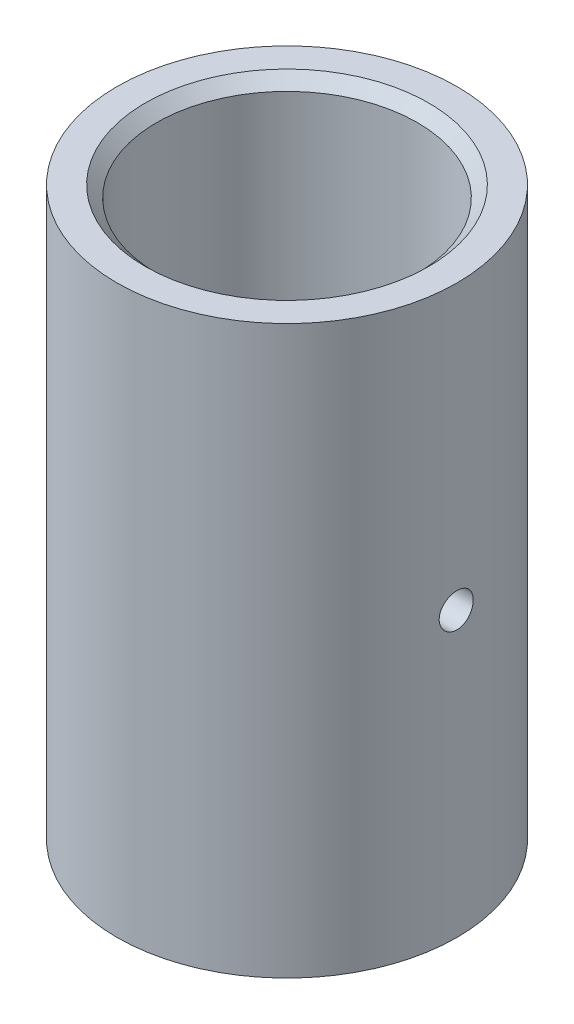
from build123d import *

# Parameters (mm, degrees)
SKETCH1_R                      = 7.5
BOSS_EXTRUDE1_DEPTH            = 25
SKETCH2_R                      = 5.75
CUT_EXTRUDE1_DEPTH             = 11
CHAMFER1_SIZE                  = 0.5
SKETCH3_R                      = 3.5
CUT_EXTRUDE2_DEPTH             = 10
CUT_EXTRUDE3_REACH             = 9.5
SKETCH4_R                      = 0.75
CUT_EXTRUDE3_DIRECTION_2_REACH = 9.5


with BuildPart() as part:
    # Sketch1 → Boss-Extrude1 (new body)
    with BuildSketch(Plane(origin=(0, 0, 0), x_dir=(1, 0, 0), z_dir=(0, 1, 0))):
        Circle(SKETCH1_R)
    extrude(amount=BOSS_EXTRUDE1_DEPTH)

    # Sketch2 → Cut-Extrude1 (cut)
    with BuildSketch(Plane(origin=(0, 25, 0), x_dir=(1, 0, 0), z_dir=(0, 1, 0))):
        Circle(SKETCH2_R)
    extrude(amount=-CUT_EXTRUDE1_DEPTH, mode=Mode.SUBTRACT)

    # Chamfer1
    chamfer1_edges = [part.edges().sort_by_distance(p)[0] for p in [
        (-5.75, 25, 0),
    ]]
    chamfer(chamfer1_edges, length=CHAMFER1_SIZE)

    # Sketch3 → Cut-Extrude2 (cut)
    with BuildSketch(Plane(origin=(0, 14, 0), x_dir=(1, 0, 0), z_dir=(0, 1, 0))):
        Circle(SKETCH3_R)
    extrude(amount=-CUT_EXTRUDE2_DEPTH, mode=Mode.SUBTRACT)

    # Sketch4 → Cut-Extrude3 (cut, up to next)
    with BuildSketch(Plane(origin=(0, 0, 0), x_dir=(0, 0, -1), z_dir=(1, 0, 0)), mode=Mode.PRIVATE) as cut_extrude3_sk1:
        with Locations((0, 12.5)):
            Circle(SKETCH4_R)
    cut_extrude3_tool1 = extrude(cut_extrude3_sk1.sketch, amount=-CUT_EXTRUDE3_REACH, mode=Mode.PRIVATE) & part.part
    add(cut_extrude3_tool1.solids().sort_by_distance((0, 12.5, 0))[0], mode=Mode.SUBTRACT)

    # Sketch4 → Cut-Extrude3 direction 2 (cut, up to next)
    with BuildSketch(Plane(origin=(0, 0, 0), x_dir=(0, 0, -1), z_dir=(1, 0, 0)), mode=Mode.PRIVATE) as cut_extrude3_direction_2_sk1:
        with Locations((0, 12.5)):
            Circle(SKETCH4_R)
    cut_extrude3_direction_2_tool1 = extrude(cut_extrude3_direction_2_sk1.sketch, amount=CUT_EXTRUDE3_DIRECTION_2_REACH, mode=Mode.PRIVATE) & part.part
    add(cut_extrude3_direction_2_tool1.solids().sort_by_distance((0, 12.5, 0))[0], mode=Mode.SUBTRACT)


solid = part.part
